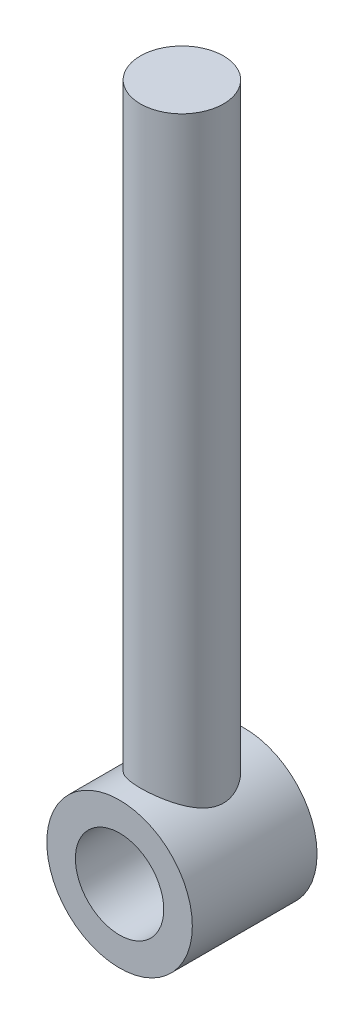
from build123d import *

# Parameters (mm, degrees)
BOSS_EXTRUDE1_DEPTH         = 9.525
BOSS_EXTRUDE1_DEPTH_BACK    = 9.525
SKETCH1_R                   = 11.1125
SKETCH2_R                   = 6.35
BOSS_EXTRUDE2_DEPTH         = 101.6
F_1_2_CLEARANCE_HOLE1_D     = 13.49248
F_1_2_CLEARANCE_HOLE1_DEPTH = 63.5
F_1_2_CLEARANCE_HOLE1_TIP   = 4.053549943


with BuildPart() as part:
    # Sketch1 → Boss-Extrude1 (new, two sides: drawn at the far end of the back side and taken through both)
    with BuildSketch(Plane.XY.offset(-BOSS_EXTRUDE1_DEPTH_BACK)):
        Circle(SKETCH1_R)
    extrude(amount=BOSS_EXTRUDE1_DEPTH + BOSS_EXTRUDE1_DEPTH_BACK)

    # Sketch2 → Boss-Extrude2 (add)
    with BuildSketch(Plane(origin=(0, 0, 0), x_dir=(1, 0, 0), z_dir=(0, 1, 0))):
        Circle(SKETCH2_R)
    extrude(amount=BOSS_EXTRUDE2_DEPTH)

    # 1_2 Clearance Hole1
    with Locations(Plane.XY.offset(9.525)):
        with Locations((0, 0)):
            Hole(F_1_2_CLEARANCE_HOLE1_D / 2, depth=F_1_2_CLEARANCE_HOLE1_DEPTH)
            with Locations((0, 0, -(F_1_2_CLEARANCE_HOLE1_DEPTH + F_1_2_CLEARANCE_HOLE1_TIP / 2))):  # 118° drill point
                Cone(0, F_1_2_CLEARANCE_HOLE1_D / 2, F_1_2_CLEARANCE_HOLE1_TIP, mode=Mode.SUBTRACT)


solid = part.part
